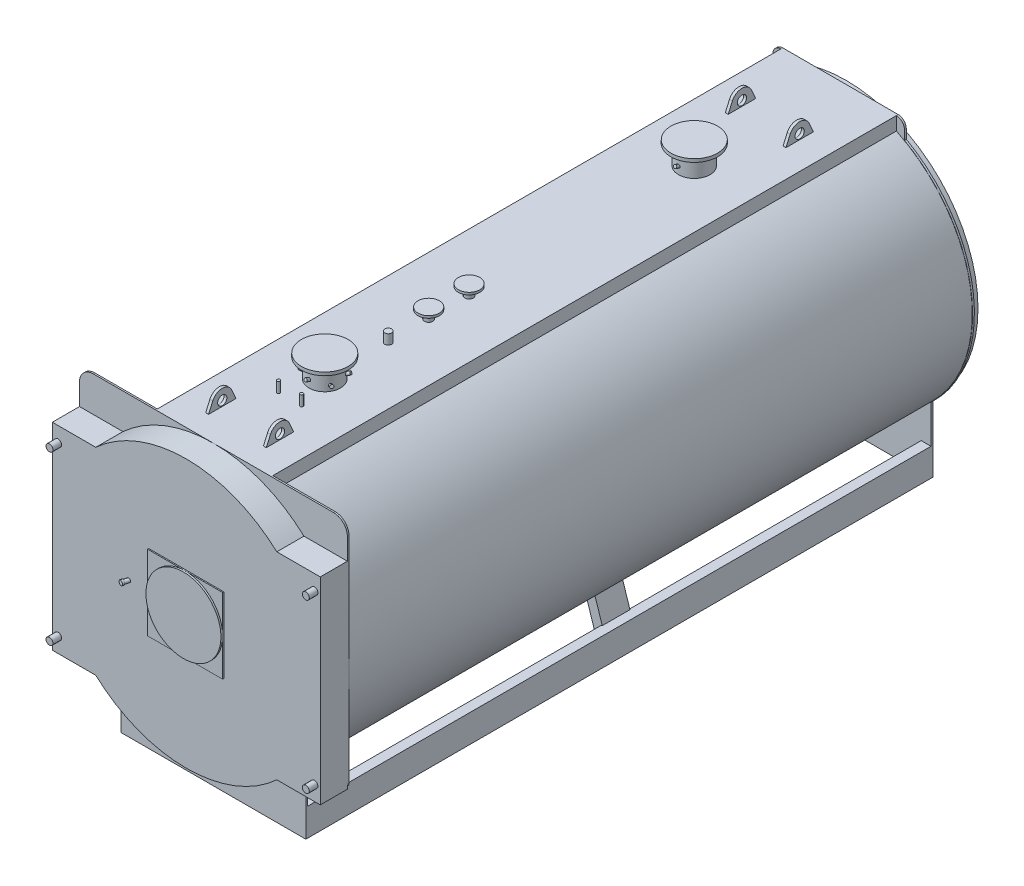
from build123d import *

# Parameters (mm, degrees)
PIASTRA_ANTERIORE_DEPTH       = 14
CORPO_DEPTH                   = 5400
PIASTRA_POSTERIORE_DEPTH      = 16
BASAMENTO_DEPTH               = 5400
ESTRUSIONE_ESTRUSIONE16_DEPTH = 120
ESTRUSIONE_ESTRUSIONE3_DEPTH  = 235
SCHIZZO8_W                    = 650
SCHIZZO8_H                    = 650
ESTRUSIONE_ESTRUSIONE4_DEPTH  = 10
SCHIZZO9_R                    = 325
ESTRUSIONE_ESTRUSIONE5_DEPTH  = 15
SCHIZZO12_R                   = 30
ESTRUSIONE_ESTRUSIONE6_DEPTH  = 75
SCHIZZO13_R                   = 136.5
ESTRUSIONE_ESTRUSIONE7_DEPTH  = 1355
SCHIZZO14_R                   = 202.5
ESTRUSIONE_ESTRUSIONE8_DEPTH  = 28
SCHIZZO13_3_R                 = 36.5
ESTRUSIONE_ESTRUSIONE9_DEPTH  = 1250
SCHIZZO15_R                   = 92.5
ESTRUSIONE_ESTRUSIONE10_DEPTH = 20
SCHIZZO13_4_R                 = 30.15
ESTRUSIONE_ESTRUSIONE11_DEPTH = 1245
SCHIZZO13_5_R                 = 13.35
ESTRUSIONE_ESTRUSIONE12_DEPTH = 1250
RIPETIZIONECIRCOLARE1_COUNT   = 3
SCHIZZO21_R                   = 24.15
ESTRUSIONE_ESTRUSIONE13_DEPTH = 149
SCHIZZO21_3_R                 = 24.15
ESTRUSIONE_ESTRUSIONE14_DEPTH = 50
SCHIZZO22_R                   = 75
ESTRUSIONE_ESTRUSIONE15_DEPTH = 16
GOLFARE_START                 = 250
SCHIZZO23_R                   = 40
GOLFARE_DEPTH                 = 12.5


with BuildPart() as part:
    # Schizzo1 → piastra anteriore (new body)
    with BuildSketch(Plane.XY):
        with BuildLine():
            Line((-1040, 2570), (1040, 2570))
            ThreePointArc((1040, 2570), (1124.852813742, 2534.852813742), (1160, 2450))
            Line((1160, 2450), (1160, 595))
            ThreePointArc((1160, 595), (1148.284271247, 566.715728753), (1120, 555))
            Line((1120, 555), (800, 555))
            Line((800, 555), (800, 0))
            Line((800, 0), (-800, 0))
            Line((-800, 0), (-800, 555))
            Line((-800, 555), (-1120, 555))
            ThreePointArc((-1120, 555), (-1148.284271247, 566.715728753), (-1160, 595))
            Line((-1160, 595), (-1160, 2450))
            ThreePointArc((-1160, 2450), (-1124.852813742, 2534.852813742), (-1040, 2570))
        make_face()
    extrude(amount=-PIASTRA_ANTERIORE_DEPTH)

    # Schizzo2 → corpo (add)
    with BuildSketch(Plane(origin=(0, 0, -14), x_dir=(-1, 0, 0), z_dir=(0, 0, -1))):
        with BuildLine():
            Line((500, 2453.937857346), (500, 2570))
            Line((500, 2570), (-500, 2570))
            Line((-500, 2570), (-500, 2453.937857346))
            ThreePointArc((-500, 2453.937857346), (0, 252.5), (500, 2453.937857346))
        make_face()
        with BuildLine():
            Line((490, 2447.620474933), (490, 2560))
            Line((490, 2560), (-490, 2560))
            Line((-490, 2560), (-490, 2447.620474933))
            ThreePointArc((-490, 2447.620474933), (0, 262.5), (490, 2447.620474933))
        make_face(mode=Mode.SUBTRACT)
    extrude(amount=CORPO_DEPTH)

    # Schizzo3 → piastra posteriore (add)
    with BuildSketch(Plane(origin=(0, 0, -5414), x_dir=(-1, 0, 0), z_dir=(0, 0, -1))):
        with BuildLine():
            Line((-570, 2420.296986039), (-570, 2500))
            ThreePointArc((-570, 2500), (-549.497474683, 2549.497474683), (-500, 2570))
            Line((-500, 2570), (500, 2570))
            ThreePointArc((500, 2570), (549.497474683, 2549.497474683), (570, 2500))
            Line((570, 2500), (570, 2420.296986039))
            ThreePointArc((570, 2420.296986039), (1151.140623094, 1553.091809212), (800, 570))
            Line((800, 570), (800, 0))
            Line((800, 0), (-800, 0))
            Line((-800, 0), (-800, 570))
            ThreePointArc((-800, 570), (-1151.140623094, 1553.091809212), (-570, 2420.296986039))
        make_face()
    extrude(amount=PIASTRA_POSTERIORE_DEPTH)

    # Schizzo5 → camera fumo (revolve)
    with BuildSketch(Plane(origin=(0, 0, 0), x_dir=(0, 0, -1), z_dir=(1, 0, 0)), mode=Mode.PRIVATE) as camera_fumo_sk:
        Polygon((5481, 1759), (5584, 1759), (5584, 1800), (5589, 1800), (5589, 1754), (5481, 1754), (5481, 1410), (5430, 1410), (5430, 2550), (5481, 2550), align=None)
    revolve(camera_fumo_sk.sketch.rotate(Axis((0, 1410, -5414), (0, 0, -1)), 90), axis=Axis((0, 1410, -5414), (0, 0, -1)))  # turned: the seam where the file's is

    # Schizzo6 → basamento (add)
    with BuildSketch(Plane(origin=(0, 0, -14), x_dir=(-1, 0, 0), z_dir=(0, 0, -1))):
        Polygon((-715, 0), (-800, 0), (-800, 240), (-715, 240), (-715, 230), (-790, 230), (-790, 10), (-715, 10), align=None)
    basamento = extrude(amount=BASAMENTO_DEPTH)

    # Schizzo24 → Estrusione-Estrusione16 (add, symmetric)
    with BuildSketch(Plane(origin=(0, 0, -2765), x_dir=(-1, 0, 0), z_dir=(0, 0, -1))):
        with BuildLine():
            Line((-652.504771932, 453.943635236), (-800, 0))
            Line((-800, 0), (-710.62571094, 0))
            Line((-710.62571094, 0), (-578.283784032, 407.306569721))
            ThreePointArc((-578.283784032, 407.306569721), (-615.835912678, 429.922258871), (-652.504771932, 453.943635236))
        make_face()
    estrusione_estrusione16 = extrude(amount=ESTRUSIONE_ESTRUSIONE16_DEPTH, both=True)

    # Specchia2: basamento, Estrusione-Estrusione16 across plane
    add(basamento.mirror(Plane(origin=(0, 0, 0), x_dir=(0, 0, 1), z_dir=(1, 0, 0))))
    add(estrusione_estrusione16.mirror(Plane(origin=(0, 0, 0), x_dir=(0, 0, 1), z_dir=(1, 0, 0))))

    # Schizzo7 → Estrusione-Estrusione3 (add)
    with BuildSketch(Plane.XY):
        with BuildLine():
            Line((783.948340135, 2265), (1160, 2265))
            Line((1160, 2265), (1160, 555))
            Line((1160, 555), (783.948340135, 555))
            ThreePointArc((783.948340135, 555), (0, 250), (-783.948340135, 555))
            Line((-783.948340135, 555), (-1160, 555))
            Line((-1160, 555), (-1160, 2265))
            Line((-1160, 2265), (-783.948340135, 2265))
            ThreePointArc((-783.948340135, 2265), (0, 2570), (783.948340135, 2265))
        make_face()
    extrude(amount=ESTRUSIONE_ESTRUSIONE3_DEPTH)

    # Schizzo8 → Estrusione-Estrusione4 (add)
    with BuildSketch(Plane.XY.offset(235)):
        with Locations((0, 1410)):
            Rectangle(SCHIZZO8_W, SCHIZZO8_H)
    extrude(amount=ESTRUSIONE_ESTRUSIONE4_DEPTH)

    # Schizzo9 → Estrusione-Estrusione5 (add)
    with BuildSketch(Plane.XY.offset(245)):
        with Locations((0, 1410)):
            Circle(SCHIZZO9_R)
    extrude(amount=ESTRUSIONE_ESTRUSIONE5_DEPTH)

    # Schizzo11 → Rivoluzione2 (revolve)
    with BuildSketch(Plane(origin=(0, 1410, 0), x_dir=(1, 0, 0), z_dir=(0, 1, 0)), mode=Mode.PRIVATE) as rivoluzione2_sk:
        Polygon((-514.268693957, -288.251490803), (-496.162357162, -220.677721947), (-480.031395863, -225), (-493.996627936, -277.118955636), (-490.809072709, -277.973058485), (-494.950177431, -293.427871705), align=None)
    revolve(rivoluzione2_sk.sketch.rotate(Axis((-500, 1410, 235), (-0.258819045, 0, 0.965925826)), 180), axis=Axis((-500, 1410, 235), (-0.258819045, 0, 0.965925826)))  # turned: the seam where the file's is

    # Schizzo12 → Estrusione-Estrusione6 (add)
    with BuildSketch(Plane.XY.offset(235)):
        with Locations((-1110, 2135)):
            Circle(SCHIZZO12_R)
        with Locations(Location((1110, 2135, 0), (0, 0, 180))):  # turned: the seam where the file's is
            Circle(SCHIZZO12_R)
        with Locations((1110, 685)):
            Circle(SCHIZZO12_R)
        with Locations(Location((-1110, 685, 0), (0, 0, 180))):  # turned: the seam where the file's is
            Circle(SCHIZZO12_R)
    extrude(amount=ESTRUSIONE_ESTRUSIONE6_DEPTH)

    # Schizzo13 → Estrusione-Estrusione7 (add)
    with BuildSketch(Plane(origin=(0, 1410, 0), x_dir=(1, 0, 0), z_dir=(0, 1, 0))):
        with Locations(Location((0, 964, 0), (0, 0, 270))):  # turned: the seam where the file's is
            Circle(SCHIZZO13_R)
        with Locations(Location((0, 4164, 0), (0, 0, 270))):  # turned: the seam where the file's is
            Circle(SCHIZZO13_R)
    extrude(amount=ESTRUSIONE_ESTRUSIONE7_DEPTH)

    # Schizzo14 → Estrusione-Estrusione8 (add)
    with BuildSketch(Plane(origin=(0, 2765, 0), x_dir=(1, 0, 0), z_dir=(0, 1, 0))):
        with Locations(Location((0, 964, 0), (0, 0, 270))):  # turned: the seam where the file's is
            Circle(SCHIZZO14_R)
        with Locations(Location((0, 4164, 0), (0, 0, 270))):  # turned: the seam where the file's is
            Circle(SCHIZZO14_R)
    extrude(amount=-ESTRUSIONE_ESTRUSIONE8_DEPTH)

    # Schizzo13_3 → Estrusione-Estrusione9 (add)
    with BuildSketch(Plane(origin=(0, 1410, 0), x_dir=(1, 0, 0), z_dir=(0, 1, 0))):
        with Locations(Location((0, 2214, 0), (0, 0, 270))):  # turned: the seam where the file's is
            Circle(SCHIZZO13_3_R)
        with Locations(Location((0, 1864, 0), (0, 0, 270))):  # turned: the seam where the file's is
            Circle(SCHIZZO13_3_R)
    extrude(amount=ESTRUSIONE_ESTRUSIONE9_DEPTH)

    # Schizzo15 → Estrusione-Estrusione10 (add)
    with BuildSketch(Plane(origin=(0, 2660, 0), x_dir=(1, 0, 0), z_dir=(0, 1, 0))):
        with Locations(Location((0, 2214, 0), (0, 0, 270))):  # turned: the seam where the file's is
            Circle(SCHIZZO15_R)
        with Locations(Location((0, 1864, 0), (0, 0, 270))):  # turned: the seam where the file's is
            Circle(SCHIZZO15_R)
    extrude(amount=-ESTRUSIONE_ESTRUSIONE10_DEPTH)

    # Schizzo13_4 → Estrusione-Estrusione11 (add)
    with BuildSketch(Plane(origin=(0, 1410, 0), x_dir=(1, 0, 0), z_dir=(0, 1, 0))):
        with Locations(Location((0, 1514, 0), (0, 0, 270))):  # turned: the seam where the file's is
            Circle(SCHIZZO13_4_R)
    extrude(amount=ESTRUSIONE_ESTRUSIONE11_DEPTH)

    # Schizzo13_5 → Estrusione-Estrusione12 (add)
    with BuildSketch(Plane(origin=(0, 1410, 0), x_dir=(1, 0, 0), z_dir=(0, 1, 0))):
        with Locations(Location((-100, 664, 0), (0, 0, 270))):  # turned: the seam where the file's is
            Circle(SCHIZZO13_5_R)
        with Locations(Location((100, 664, 0), (0, 0, 270))):  # turned: the seam where the file's is
            Circle(SCHIZZO13_5_R)
    extrude(amount=ESTRUSIONE_ESTRUSIONE12_DEPTH)

    # Schizzo16 → Rivoluzione3 (revolve)
    with BuildSketch(Plane(origin=(0, 0, 0), x_dir=(0, 0, -1), z_dir=(1, 0, 0))):
        Polygon((3998.199829072, 2645.664390077), (4002.8, 2658.303255826), (4049.784631039, 2641.20224866), (4045.184460112, 2628.56338291), align=None)
    revolve(axis=Axis((0, 2635, -4027.5), (0, 0.342020143, 0.939692621)))

    # Schizzo17 → Rivoluzione4 (revolve)
    with BuildSketch(Plane(origin=(0, 0, 0), x_dir=(0, 0, -1), z_dir=(1, 0, 0))):
        Polygon((798.199829072, 2645.664390077), (802.8, 2658.303255826), (849.784631039, 2641.20224866), (845.184460112, 2628.56338291), align=None)
    rivoluzione4 = revolve(axis=Axis((0, 2635, -827.5), (0, 0.342020143, 0.939692621)))

    # Schizzo18 → Rivoluzione5 (revolve)
    with BuildSketch(Plane(origin=(0, 0, 0), x_dir=(0, 0, -1), z_dir=(1, 0, 0))):
        Polygon((1129.800170928, 2625.664390077), (1125.2, 2638.303255826), (1078.215368961, 2621.20224866), (1082.815539888, 2608.56338291), align=None)
    rivoluzione5 = revolve(axis=Axis((0, 2615, -1100.5), (0, -0.342020143, 0.939692621)))

    # RipetizioneCircolare1: Rivoluzione4, Rivoluzione5 ×3 about axis
    ripetizionecircolare1_axis = Axis((0, 0, -964), (0, 1, 0))
    add([rivoluzione4.rotate(ripetizionecircolare1_axis, i * 360 / RIPETIZIONECIRCOLARE1_COUNT) for i in range(1, RIPETIZIONECIRCOLARE1_COUNT)])
    add([rivoluzione5.rotate(ripetizionecircolare1_axis, i * 360 / RIPETIZIONECIRCOLARE1_COUNT) for i in range(1, RIPETIZIONECIRCOLARE1_COUNT)])

    # Schizzo21 → Estrusione-Estrusione13 (add)
    with BuildSketch(Plane(origin=(0, 0, -5430), x_dir=(-1, 0, 0), z_dir=(0, 0, -1))):
        with Locations((0, 125)):
            Circle(SCHIZZO21_R)
    extrude(amount=ESTRUSIONE_ESTRUSIONE13_DEPTH)

    # Schizzo21_3 → Estrusione-Estrusione14 (add)
    with BuildSketch(Plane(origin=(0, 0, -5430), x_dir=(-1, 0, 0), z_dir=(0, 0, -1))):
        with Locations((0, 260)):
            Circle(SCHIZZO21_3_R)
    extrude(amount=ESTRUSIONE_ESTRUSIONE14_DEPTH)

    # Schizzo22 → Estrusione-Estrusione15 (add)
    with BuildSketch(Plane(origin=(0, 0, -5579), x_dir=(-1, 0, 0), z_dir=(0, 0, -1))):
        with Locations((0, 125)):
            Circle(SCHIZZO22_R)
    extrude(amount=-ESTRUSIONE_ESTRUSIONE15_DEPTH)

    # Schizzo23 → golfare (add, symmetric)
    with BuildSketch(Plane(origin=(0, 0, 0), x_dir=(0, 0, -1), z_dir=(1, 0, 0)).offset(GOLFARE_START)):
        with BuildLine():
            Line((189, 2476), (189, 2556))
            Line((189, 2556), (231.707899924, 2652.441875159))
            ThreePointArc((231.707899924, 2652.441875159), (314, 2706), (396.292100076, 2652.441875159))
            Line((396.292100076, 2652.441875159), (439, 2556))
            Line((439, 2556), (439, 2476))
            Line((439, 2476), (189, 2476))
        make_face()
        with Locations((314, 2616)):
            Circle(SCHIZZO23_R, mode=Mode.SUBTRACT)
        with BuildLine():
            Line((4689, 2476), (4689, 2556))
            Line((4689, 2556), (4731.707899924, 2652.441875159))
            ThreePointArc((4731.707899924, 2652.441875159), (4814, 2706), (4896.292100076, 2652.441875159))
            Line((4896.292100076, 2652.441875159), (4939, 2556))
            Line((4939, 2556), (4939, 2476))
            Line((4939, 2476), (4689, 2476))
        make_face()
        with Locations((4814, 2616)):
            Circle(SCHIZZO23_R, mode=Mode.SUBTRACT)
    golfare = extrude(amount=GOLFARE_DEPTH, both=True)

    # Specchia3: golfare across plane
    add(golfare.mirror(Plane(origin=(0, 0, 0), x_dir=(0, 0, 1), z_dir=(1, 0, 0))))


solid = part.part
